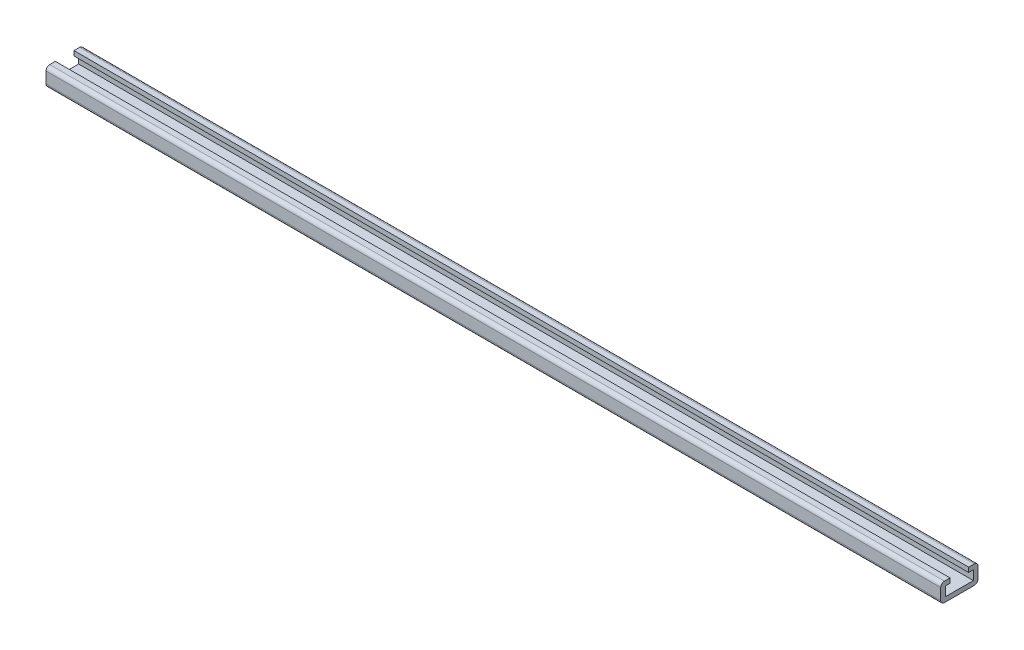
from build123d import *

# Parameters (mm, degrees)
BOSS_EXTRUDE1_DEPTH         = 609.6
FILLET1_R                   = 2.54
F_1_4_CLEARANCE_HOLE1_D     = 6.5278
F_1_4_CLEARANCE_HOLE1_DEPTH = 22.352
F_1_4_CLEARANCE_HOLE1_TIP   = 1.961148974


with BuildPart() as part:
    # Sketch1 → Boss-Extrude1 (new body)
    with BuildSketch(Plane(origin=(0, 0, 0), x_dir=(0, 0, -1), z_dir=(1, 0, 0))):
        Polygon((0, 0), (-12.7, 0), (-12.7, 12.7), (-6.35, 12.7), (-6.35, 9.525), (-9.525, 9.525), (-9.525, 3.175), (0, 3.175), align=None)
    boss_extrude1 = extrude(amount=BOSS_EXTRUDE1_DEPTH)

    # Mirror1: Boss-Extrude1 across plane
    add(boss_extrude1.mirror(Plane(origin=(609.6, 3.175, 0), x_dir=(1, 0, 0), z_dir=(0, 0, 1))))

    # Fillet1
    fillet1_edges = [part.edges().sort_by_distance(p)[0] for p in [
        (304.8, 0, 12.7),
        (304.8, 12.7, 12.7),
        (304.8, 0, -12.7),
        (304.8, 12.7, -12.7),
    ]]
    fillet(fillet1_edges, radius=FILLET1_R)

    # 1/4 Clearance Hole1
    with Locations(Plane(origin=(0, 3.175, 0), x_dir=(1, 0, 0), z_dir=(0, 1, 0))):
        with Locations((25.4, 0), (533.4, 0)):
            Hole(F_1_4_CLEARANCE_HOLE1_D / 2, depth=F_1_4_CLEARANCE_HOLE1_DEPTH)
            with Locations((0, 0, -(F_1_4_CLEARANCE_HOLE1_DEPTH + F_1_4_CLEARANCE_HOLE1_TIP / 2))):  # 118° drill point
                Cone(0, F_1_4_CLEARANCE_HOLE1_D / 2, F_1_4_CLEARANCE_HOLE1_TIP, mode=Mode.SUBTRACT)


solid = part.part
